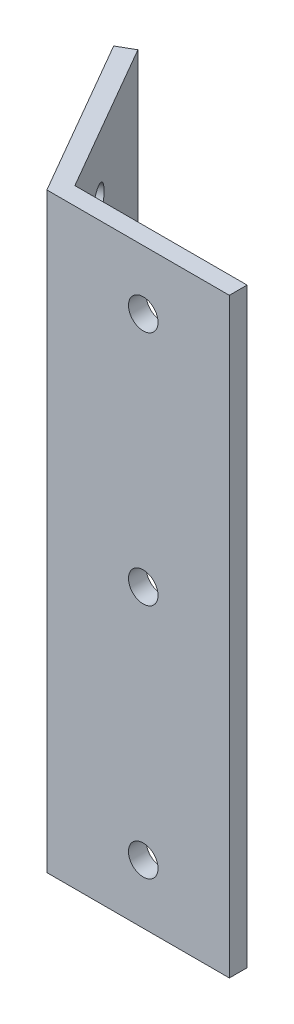
from build123d import *

# Parameters (mm, degrees)
EXTRUDE_THIN1_DEPTH = 100
SKETCH2_R           = 2.5
CUT_EXTRUDE1_DEPTH  = 10
SKETCH3_R           = 2.5
CUT_EXTRUDE2_DEPTH  = 10


with BuildPart() as part:
    # Sketch1 → Extrude-Thin1 (new body)
    with BuildSketch(Plane(origin=(0, 0, 0), x_dir=(1, 0, 0), z_dir=(0, 1, 0))):
        Polygon((-16.299038106, 25.230762114), (-0.866025404, -1.5), (30, -1.5), (30, 1.5), (0.866025404, 1.5), (-13.700961894, 26.730762114), align=None)
    extrude(amount=EXTRUDE_THIN1_DEPTH)

    # Sketch2 → Cut-Extrude1 (cut)
    with BuildSketch(Plane(origin=(1.299038106, 0, -0.75), x_dir=(-0.5, 0, -0.866025404), z_dir=(0.866025404, 0, -0.5))):
        with Locations((11.866025404, 90)):
            Circle(SKETCH2_R)
        with Locations((11.866025404, 50)):
            Circle(SKETCH2_R)
        with Locations((11.866025404, 10)):
            Circle(SKETCH2_R)
    extrude(amount=-CUT_EXTRUDE1_DEPTH, mode=Mode.SUBTRACT)

    # Sketch3 → Cut-Extrude2 (cut)
    with BuildSketch(Plane(origin=(0, 0, -1.5), x_dir=(-1, 0, 0), z_dir=(0, 0, -1))):
        with Locations((-15.433012702, 50)):
            Circle(SKETCH3_R)
        with Locations((-15.433012702, 10)):
            Circle(SKETCH3_R)
        with Locations((-15.433012702, 90)):
            Circle(SKETCH3_R)
    extrude(amount=-CUT_EXTRUDE2_DEPTH, mode=Mode.SUBTRACT)


solid = part.part
